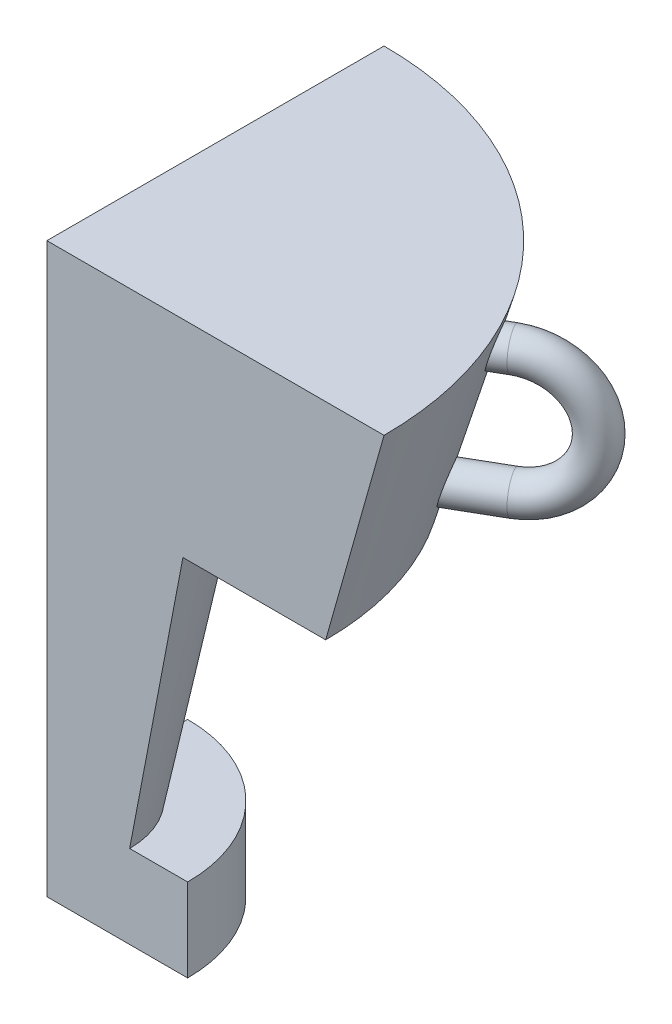
from build123d import *
from build123d.topology import SkipClean

# Parameters (mm, degrees)
ROTATION1_ANGLE                 = 90
SKIZZE5_R                       = 3
SKIZZE7_R                       = 3
AUFSATZ_LINEAR_AUSTRAGEN1_DEPTH = 7.91623


with BuildPart() as part:
    # Skizze1 → Rotation1 (revolve)
    with BuildSketch(Plane.XY):
        Polygon((0, 0), (0, 91.42015625), (54.245597194, 91.42015625), (44.858528754, 58.217747507), (21.888186449, 58.217747507), (13.314555528, 13.381302083), (22.647732611, 13.381302083), (22.647732611, 0), align=None)
    revolve(axis=Axis((0, 0, 0), (0, 1, 0)), revolution_arc=ROTATION1_ANGLE)



with BuildPart() as body_2:
    # Austragung2: sweep along a path in Skizze6
    with BuildLine(Plane(origin=(0, 0, 0), x_dir=(0.866025404, 0, -0.5), z_dir=(0.5, 0, 0.866025404))) as austragung2_path:
        Line((54.245597194, 86.42015625), (55, 86.42015625))
        ThreePointArc((55, 86.42015625), (65, 76.42015625), (55, 66.42015625))
        Line((55, 66.42015625), (54.245597194, 66.42015625))
    # Skizze5 → Austragung2 (sweep)
    with BuildSketch(Plane(origin=(46.978065214, 0, -27.122798597), x_dir=(0.5, 0, 0.866025404), z_dir=(-0.866025404, 0, 0.5))):
        with Locations((0, 86.42015625)):
            Circle(SKIZZE5_R)
    sweep(path=austragung2_path.line)


with BuildPart() as part_1:
    with SkipClean():  # keep this step's faces unmerged: merging them makes the solid invalid here
        add(part.part)

        add(body_2.part)  # Aufsatz-Linear austragen1 merges body 2
        # Skizze7 → Aufsatz-Linear austragen1 (add)
        with BuildSketch(Plane(origin=(46.978065214, 0, -27.122798597), x_dir=(0.5, 0, 0.866025404), z_dir=(-0.866025404, 0, 0.5))):
            with Locations(Location((0, 66.42015625, 0), (0, 0, 190.622906641))):  # turned: the seam where the file's is
                Circle(SKIZZE7_R)
            with Locations(Location((0, 86.42015625, 0), (0, 0, 90))):  # turned: the seam where the file's is
                Circle(SKIZZE7_R)
        extrude(amount=AUFSATZ_LINEAR_AUSTRAGEN1_DEPTH)


solid = part_1.part
